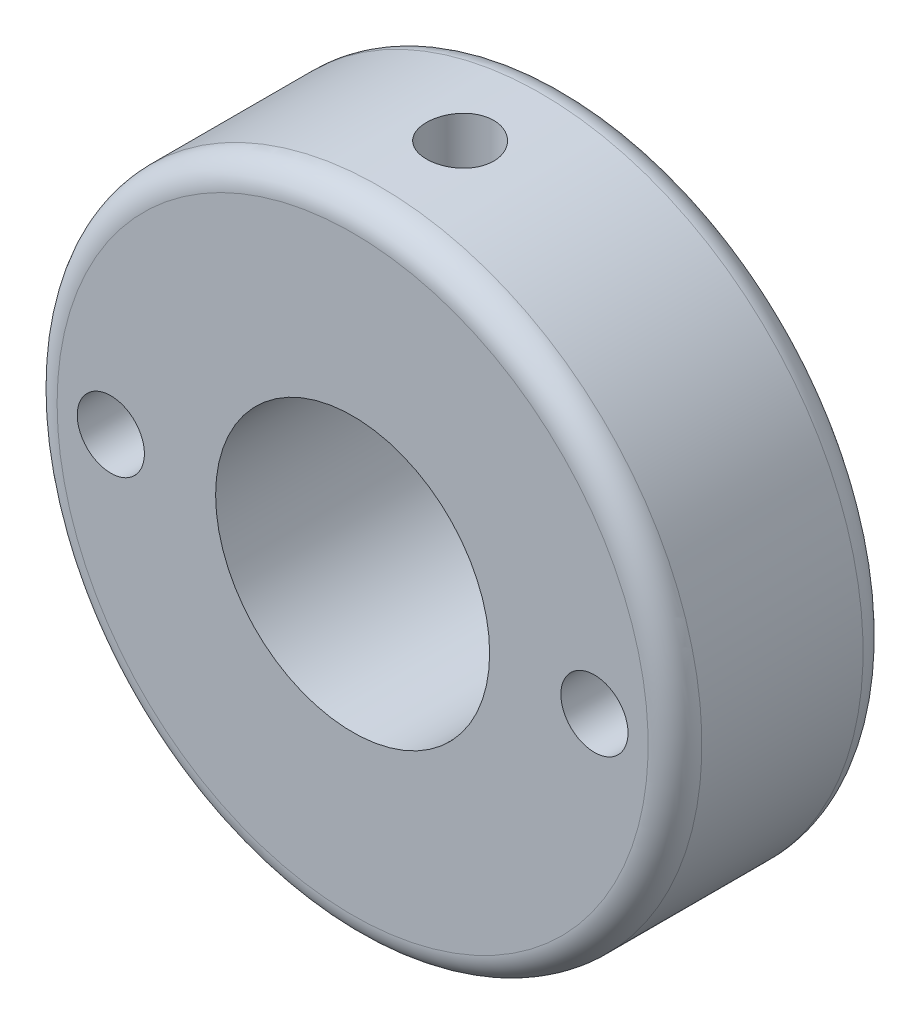
from build123d import *

# Parameters (mm, degrees)
SKETCH1_W                    = 24
SKETCH1_H                    = 24
BOSS_EXTRUDE1_DEPTH          = 8
M3_TAPPED_HOLE1_D            = 2.5
F_10_2_10_2_DIAMETER_HOLE1_D = 10.2
M3_TAPPED_HOLE2_REACH        = 30
M3_TAPPED_HOLE2_BORE_R       = 1.25
SKETCH15_R                   = 18.5
SKETCH15_R_2                 = 12
CUT_EXTRUDE2_DEPTH           = 10
FILLET2_R                    = 1


with BuildPart() as part:
    # Sketch1 → Boss-Extrude1 (new body)
    with BuildSketch(Plane.XY):
        Rectangle(SKETCH1_W, SKETCH1_H)
    extrude(amount=BOSS_EXTRUDE1_DEPTH)

    # M3 Tapped Hole1 (through all)
    with Locations(Plane.XY.offset(8)):
        with Locations((9, 0), (-9, 0)):
            Hole(M3_TAPPED_HOLE1_D / 2)

    # Ø10.2 (10.2) Diameter Hole1 (through all)
    with Locations(Plane(origin=(0, 0, 0), x_dir=(-1, 0, 0), z_dir=(0, 0, -1))):
        with Locations((0, 0)):
            Hole(F_10_2_10_2_DIAMETER_HOLE1_D / 2)

    # M3 Tapped Hole2 bore → M3 Tapped Hole2 (cut, up to next)
    with BuildSketch(Plane(origin=(0, 12, 0), x_dir=(1, 0, 0), z_dir=(0, 1, 0)), mode=Mode.PRIVATE) as m3_tapped_hole2_sk1:
        with Locations((0, -4)):
            Circle(M3_TAPPED_HOLE2_BORE_R)
    m3_tapped_hole2_tool1 = extrude(m3_tapped_hole2_sk1.sketch, amount=-M3_TAPPED_HOLE2_REACH, mode=Mode.PRIVATE) & part.part
    add(m3_tapped_hole2_tool1.solids().sort_by_distance((0, 12, 4))[0], mode=Mode.SUBTRACT)

    # Sketch15 → Cut-Extrude2 (cut)
    with BuildSketch(Plane(origin=(0, 0, 0), x_dir=(-1, 0, 0), z_dir=(0, 0, -1))):
        Circle(SKETCH15_R)
        Circle(SKETCH15_R_2, mode=Mode.SUBTRACT)
    extrude(amount=-CUT_EXTRUDE2_DEPTH, mode=Mode.SUBTRACT)

    # Fillet2
    fillet2_edges = [part.edges().sort_by_distance(p)[0] for p in [
        (12, 0, 0),
        (12, 0, 8),
    ]]
    fillet(fillet2_edges, radius=FILLET2_R)


solid = part.part
